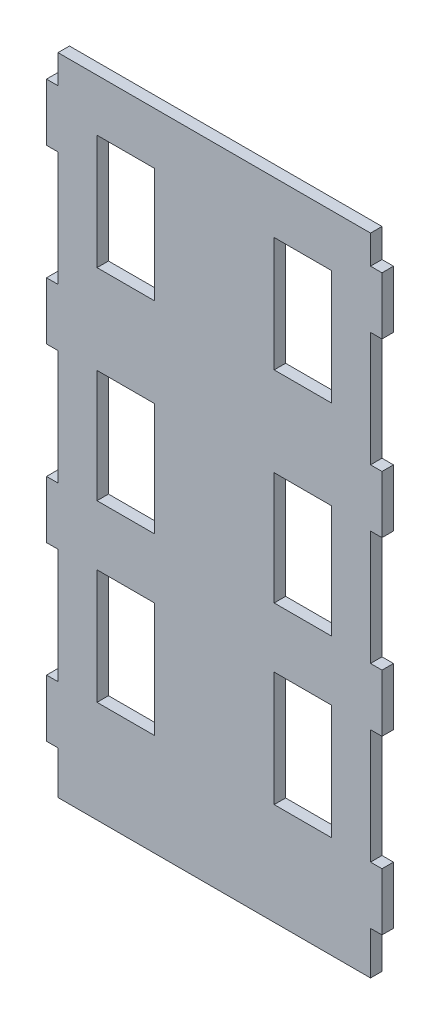
from build123d import *

# Parameters (mm, degrees)
SKETCH1_W           = 20
SKETCH1_H           = 40.02889445
SKETCH1_H_2         = 40
SKETCH1_H_3         = 39.353713997
BOSS_EXTRUDE1_DEPTH = 4


with BuildPart() as part:
    # Sketch1 → Boss-Extrude1 (new body)
    with BuildSketch(Plane.XY):
        Polygon((66.836116993, 121.125108431), (-42.163883007, 121.125108431), (-42.163883007, 111.125108431), (-46.163883007, 111.125108431), (-46.163883007, 91.125108431), (-42.163883007, 91.125108431), (-42.163883007, 51.125108431), (-46.163883007, 51.125108431), (-46.163883007, 31.125108431), (-42.163883007, 31.125108431), (-42.163883007, -8.874891569), (-46.163883007, -8.874891569), (-46.163883007, -28.874891569), (-42.163883007, -28.874891569), (-42.163883007, -68.874891569), (-46.163883007, -68.874891569), (-46.163883007, -88.874891569), (-42.163883007, -88.874891569), (-42.163883007, -103.874891569), (66.836116993, -103.874891569), (66.836116993, -88.874891569), (70.836116993, -88.874891569), (70.836116993, -68.874891569), (66.836116993, -68.874891569), (66.836116993, -28.874891569), (70.836116993, -28.874891569), (70.836116993, -8.874891569), (66.836116993, -8.874891569), (66.836116993, 31.125108431), (70.836116993, 31.125108431), (70.836116993, 51.125108431), (66.836116993, 51.125108431), (66.836116993, 91.125108431), (70.836116993, 91.125108431), (70.836116993, 111.125108431), (66.836116993, 111.125108431), align=None)
        with Locations((43.223488174, -48.291018479)):
            Rectangle(SKETCH1_W, SKETCH1_H, mode=Mode.SUBTRACT)
        with Locations((-18.551254188, 82.990248393)):
            Rectangle(SKETCH1_W, SKETCH1_H_2, mode=Mode.SUBTRACT)
        with Locations((-18.551254188, 12.271619921)):
            Rectangle(SKETCH1_W, SKETCH1_H_3, mode=Mode.SUBTRACT)
        with Locations((-18.551254188, -48.291018479)):
            Rectangle(SKETCH1_W, SKETCH1_H, mode=Mode.SUBTRACT)
        with Locations((43.223488174, 12.271619921)):
            Rectangle(SKETCH1_W, SKETCH1_H_3, mode=Mode.SUBTRACT)
        with Locations((43.223488174, 82.990248393)):
            Rectangle(SKETCH1_W, SKETCH1_H_2, mode=Mode.SUBTRACT)
    extrude(amount=BOSS_EXTRUDE1_DEPTH)


solid = part.part
